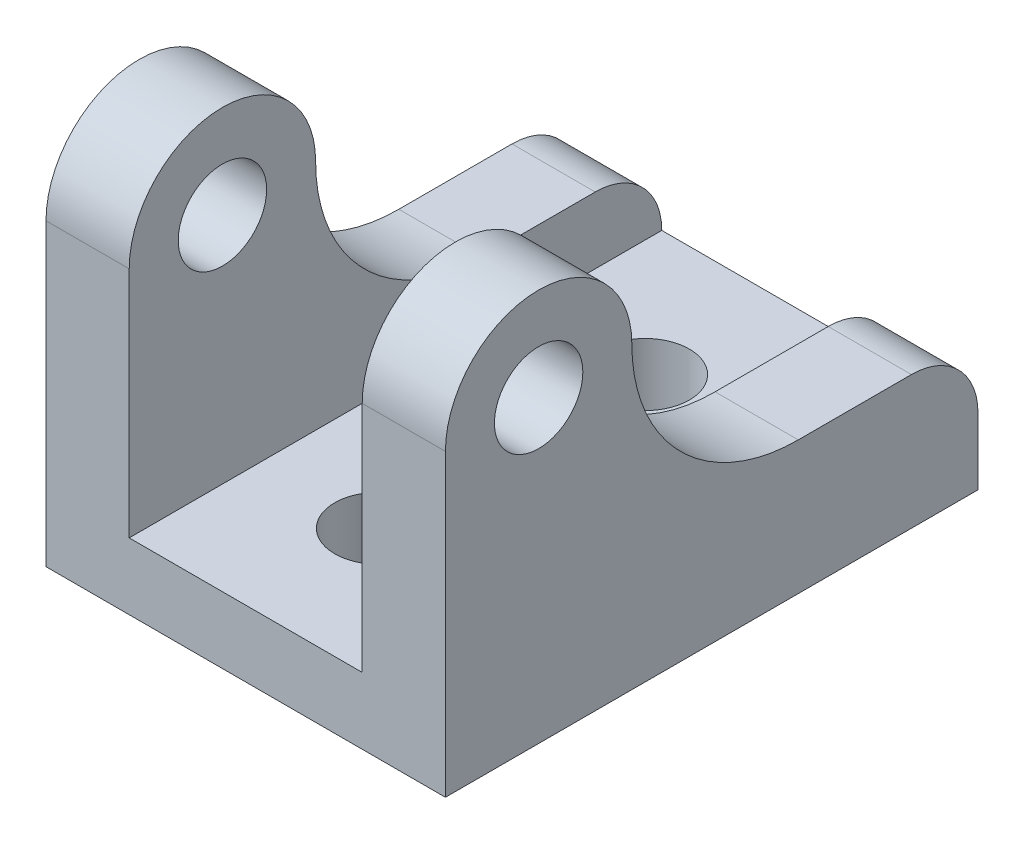
from build123d import *

# Parameters (mm, degrees)
BOSS_EXTRUDE1_DEPTH      = 50.8
F_5_16_CLEARANCE_HOLE3_D = 8.4328
CUT_EXTRUDE2_DEPTH       = 20.05
CUT_EXTRUDE2_DEPTH_BACK  = 20.05
F_5_16_CLEARANCE_HOLE2_D = 8.4328


with BuildPart() as part:
    # Sketch1 → Boss-Extrude1 (new body)
    with BuildSketch(Plane.XY):
        Polygon((-19.05, 0), (19.05, 0), (19.05, 50.8), (11.1125, 50.8), (11.1125, 6.35), (-11.1125, 6.35), (-11.1125, 50.8), (-19.05, 50.8), align=None)
    extrude(amount=BOSS_EXTRUDE1_DEPTH)

    # 5/16 Clearance Hole3 (through all)
    with Locations(Plane(origin=(0, 6.35, 0), x_dir=(1, 0, 0), z_dir=(0, 1, 0))):
        with Locations((0, -38.1), (0, -12.7)):
            Hole(F_5_16_CLEARANCE_HOLE3_D / 2)

    # Sketch18 → Cut-Extrude2 (cut, two sides)
    with BuildSketch(Plane(origin=(0, 0, 0), x_dir=(0, 0, -1), z_dir=(1, 0, 0))) as cut_extrude2_sk:
        with BuildLine():
            Line((0, 50.8), (-50.8, 50.8))
            Line((-50.8, 50.8), (-50.8, 28.575))
            ThreePointArc((-50.8, 28.575), (-41.91, 37.465), (-33.02, 28.575))
            ThreePointArc((-33.02, 28.575), (-28.370320151, 17.349679849), (-17.145, 12.7))
            Line((-17.145, 12.7), (-6.35, 12.7))
            ThreePointArc((-6.35, 12.7), (-1.859871939, 10.840128061), (0, 6.35))
            Line((0, 6.35), (0, 50.8))
        make_face()
    extrude(amount=CUT_EXTRUDE2_DEPTH, mode=Mode.SUBTRACT)
    extrude(cut_extrude2_sk.sketch, amount=-CUT_EXTRUDE2_DEPTH_BACK, mode=Mode.SUBTRACT)

    # 5/16 Clearance Hole2 (through all)
    with Locations(Plane(origin=(19.05, 0, 0), x_dir=(0, 0, -1), z_dir=(1, 0, 0))):
        with Locations((-41.91, 28.575)):
            Hole(F_5_16_CLEARANCE_HOLE2_D / 2)


solid = part.part
